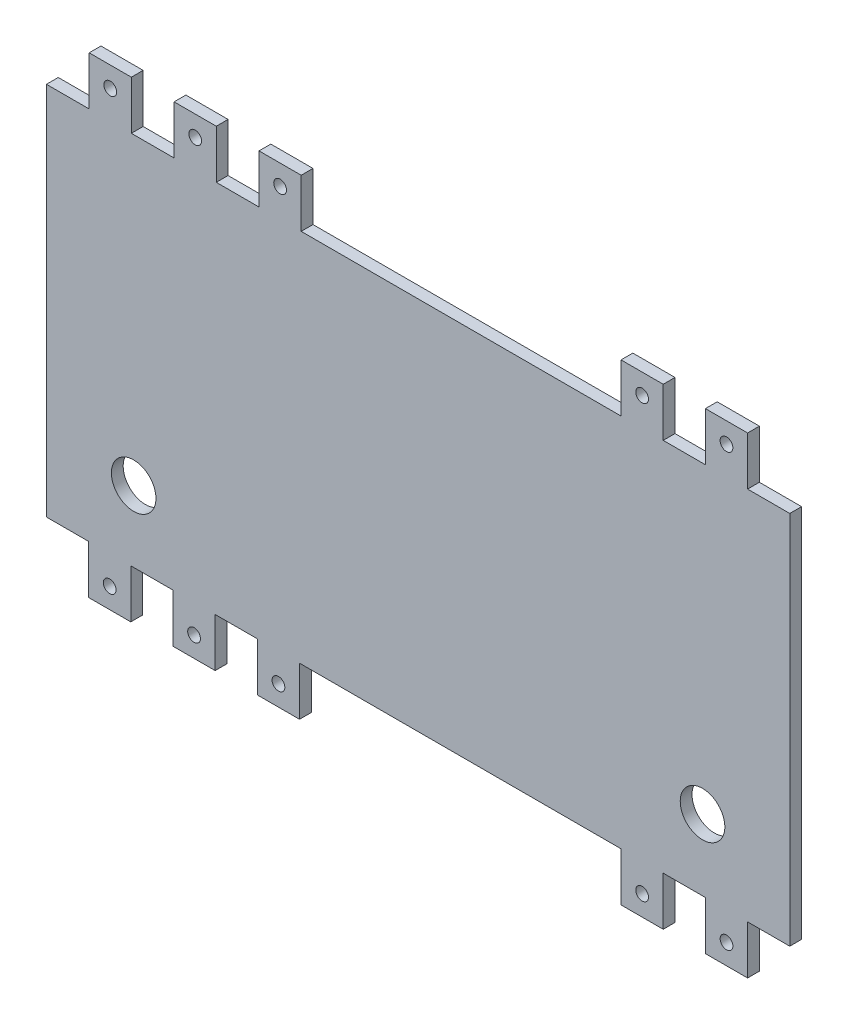
from build123d import *

# Parameters (mm, degrees)
SKETCH1_W               = 200
SKETCH1_H               = 127
BOSS_EXTRUDE1_DEPTH     = 3.175
SKETCH4_W               = 11.35
SKETCH4_H               = 13.0800094
SKETCH4_W_2             = 86.049970282
SKETCH4_W_3             = 11.50001
SKETCH4_W_4             = 86.500000282
CUT_EXTRUDE1_DEPTH      = 4.175
SKETCH5_R               = 6
CUT_EXTRUDE2_DEPTH      = 1
CUT_EXTRUDE2_DEPTH_BACK = 4.175
SKETCH6_R               = 1.7145
CUT_EXTRUDE3_DEPTH      = 4.175


with BuildPart() as part:
    # Sketch1 → Boss-Extrude1 (new body)
    with BuildSketch(Plane.XY):
        with Locations((52.222222222, -34.055555556)):
            Rectangle(SKETCH1_W, SKETCH1_H)
    extrude(amount=BOSS_EXTRUDE1_DEPTH)

    # Sketch4 → Cut-Extrude1 (cut, through all)
    with BuildSketch(Plane(origin=(0, 0, 0), x_dir=(-1, 0, 0), z_dir=(0, 0, -1))):
        with Locations((-146.547222222, 22.904439744)):
            Rectangle(SKETCH4_W, SKETCH4_H)
        with Locations((-123.847222222, 22.904439744)):
            Rectangle(SKETCH4_W, SKETCH4_H)
        with Locations((-63.797237175, 22.904439744)):
            Rectangle(SKETCH4_W_2, SKETCH4_H)
        with Locations((-3.672247128, 22.904439744)):
            Rectangle(SKETCH4_W_3, SKETCH4_H)
        with Locations((19.177762872, 22.904439744)):
            Rectangle(SKETCH4_W_3, SKETCH4_H)
        with Locations((42.027772778, 22.904439744)):
            Rectangle(SKETCH4_W_3, SKETCH4_H)
        with Locations((-146.547222222, -91.015550856)):
            Rectangle(SKETCH4_W, SKETCH4_H)
        with Locations((-123.847222222, -91.015550856)):
            Rectangle(SKETCH4_W, SKETCH4_H)
        with Locations((-63.572222175, -91.015550856)):
            Rectangle(SKETCH4_W_4, SKETCH4_H)
        with Locations((-3.297222034, -91.015550856)):
            Rectangle(SKETCH4_W, SKETCH4_H)
        with Locations((19.402777872, -91.015550856)):
            Rectangle(SKETCH4_W, SKETCH4_H)
        with Locations((42.102777778, -91.015550856)):
            Rectangle(SKETCH4_W, SKETCH4_H)
    extrude(amount=-CUT_EXTRUDE1_DEPTH, mode=Mode.SUBTRACT)

    # Sketch5 → Cut-Extrude2 (cut, two sides)
    with BuildSketch(Plane(origin=(0, 0, 0), x_dir=(-1, 0, 0), z_dir=(0, 0, -1))) as cut_extrude2_sk:
        with Locations((-128.747542222, -65.425546156)):
            Circle(SKETCH5_R)
        with Locations((24.303097778, -65.425546156)):
            Circle(SKETCH5_R)
    extrude(amount=CUT_EXTRUDE2_DEPTH, mode=Mode.SUBTRACT)
    extrude(cut_extrude2_sk.sketch, amount=-CUT_EXTRUDE2_DEPTH_BACK, mode=Mode.SUBTRACT)

    # Sketch6 → Cut-Extrude3 (cut, through all)
    with BuildSketch(Plane(origin=(0, 0, 0), x_dir=(-1, 0, 0), z_dir=(0, 0, -1))):
        with Locations((-135.197222222, 23.984435044)):
            Circle(SKETCH6_R)
        with Locations((-112.497222269, 23.984435044)):
            Circle(SKETCH6_R)
        with Locations((-15.097252081, 23.984435044)):
            Circle(SKETCH6_R)
        with Locations((7.752757872, 23.984435044)):
            Circle(SKETCH6_R)
        with Locations((30.602767825, 23.984435044)):
            Circle(SKETCH6_R)
        with Locations((-112.497222269, -92.095546156)):
            Circle(SKETCH6_R)
        with Locations((-135.197222222, -92.095546156)):
            Circle(SKETCH6_R)
        with Locations((-14.647222034, -92.095546156)):
            Circle(SKETCH6_R)
        with Locations((8.052777919, -92.095546156)):
            Circle(SKETCH6_R)
        with Locations((30.752777825, -92.095546156)):
            Circle(SKETCH6_R)
    extrude(amount=-CUT_EXTRUDE3_DEPTH, mode=Mode.SUBTRACT)


solid = part.part
